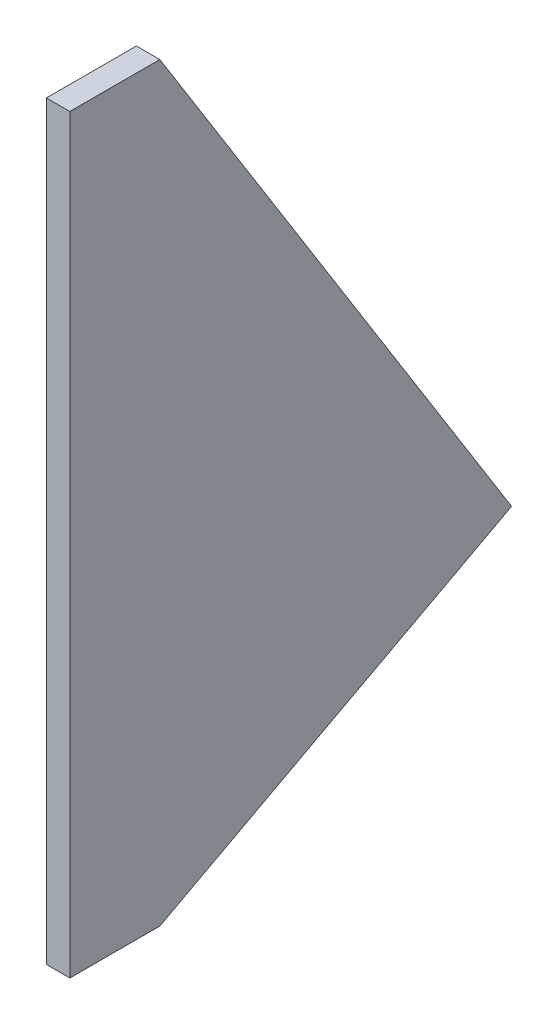
from build123d import *

# Parameters (mm, degrees)
BOSS_EXTRUDE1_DEPTH = 3.175


with BuildPart() as part:
    # Sketch1 → Boss-Extrude1 (new body, symmetric)
    with BuildSketch(Plane(origin=(0, 0, 0), x_dir=(0, 0, -1), z_dir=(1, 0, 0))):
        Polygon((0, 0), (0, 203.2), (24.3586, 203.2), (119.6086, 50.8), (24.3586, 0), align=None)
    extrude(amount=BOSS_EXTRUDE1_DEPTH, both=True)


solid = part.part
